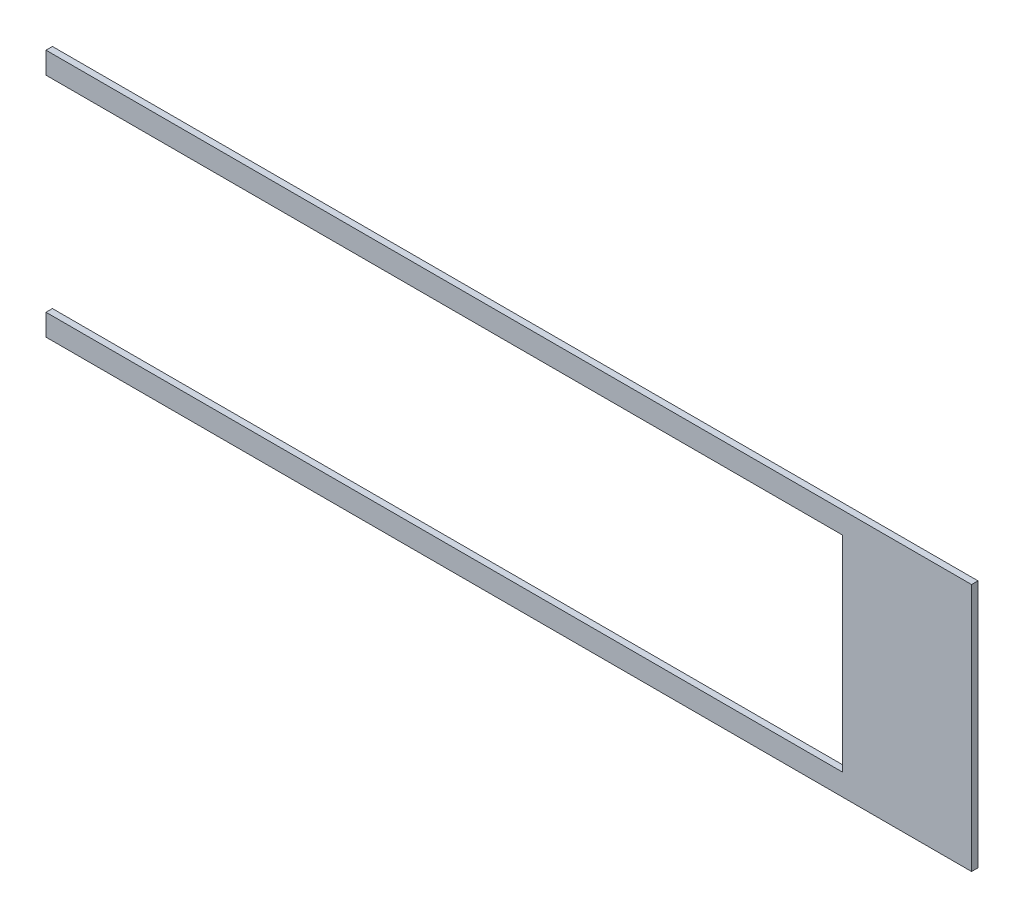
from build123d import *

# Parameters (mm, degrees)
BOSS_EXTRUDE1_DEPTH = 3.175


with BuildPart() as part:
    # Sketch1 → Boss-Extrude1 (new body)
    with BuildSketch(Plane.XY):
        Polygon((-228.7016, -61.4172), (228.7016, -61.4172), (228.7016, 61.4172), (-228.7016, 61.4172), (-228.7016, 50.6984), (164.9984, 50.6984), (164.9984, -50.7492), (-228.7016, -50.7492), align=None)
    extrude(amount=BOSS_EXTRUDE1_DEPTH)


solid = part.part
